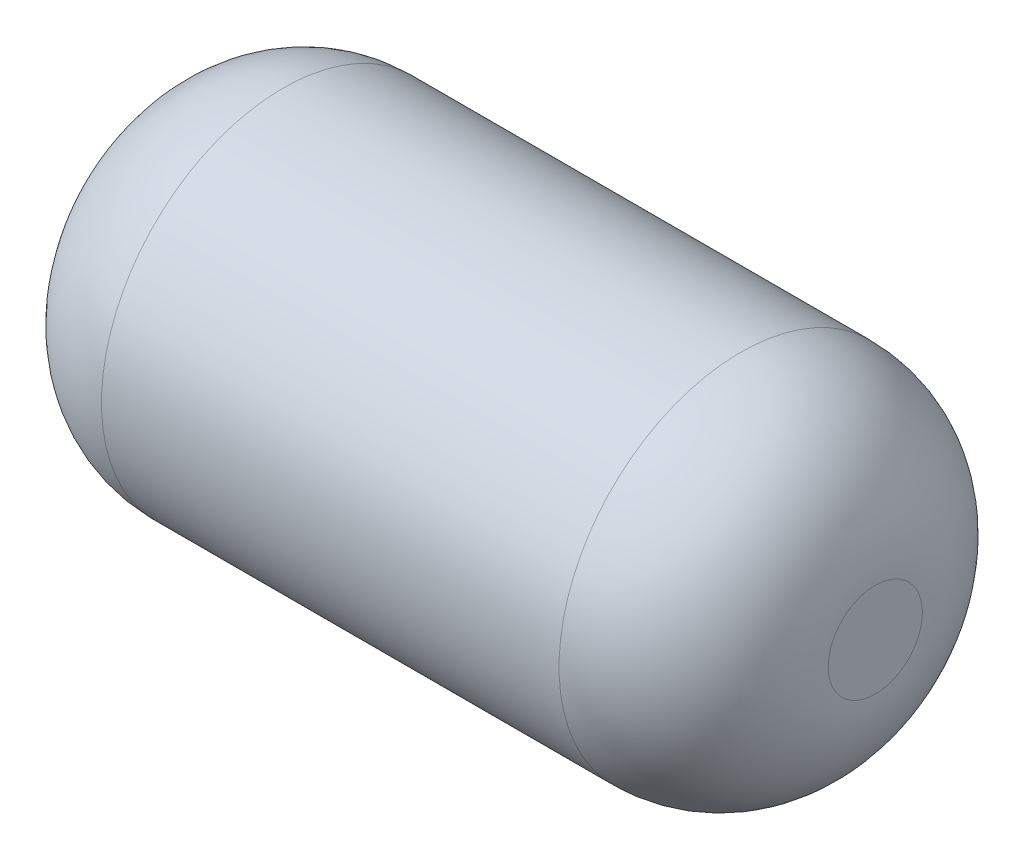
from build123d import *

# Parameters (mm, degrees)
SKETCH1_R           = 67.5
BOSS_EXTRUDE1_DEPTH = 135
FILLET1_R           = 50


with BuildPart() as part:
    # Sketch1 → Boss-Extrude1 (new body, symmetric)
    with BuildSketch(Plane(origin=(0, 0, 0), x_dir=(0, 0, -1), z_dir=(1, 0, 0))):
        Circle(SKETCH1_R)
    extrude(amount=BOSS_EXTRUDE1_DEPTH, both=True)

    # Fillet1
    fillet1_edges = [part.edges().sort_by_distance(p)[0] for p in [
        (-135, 0, 67.5),
        (135, 0, 67.5),
    ]]
    fillet(fillet1_edges, radius=FILLET1_R)


solid = part.part
